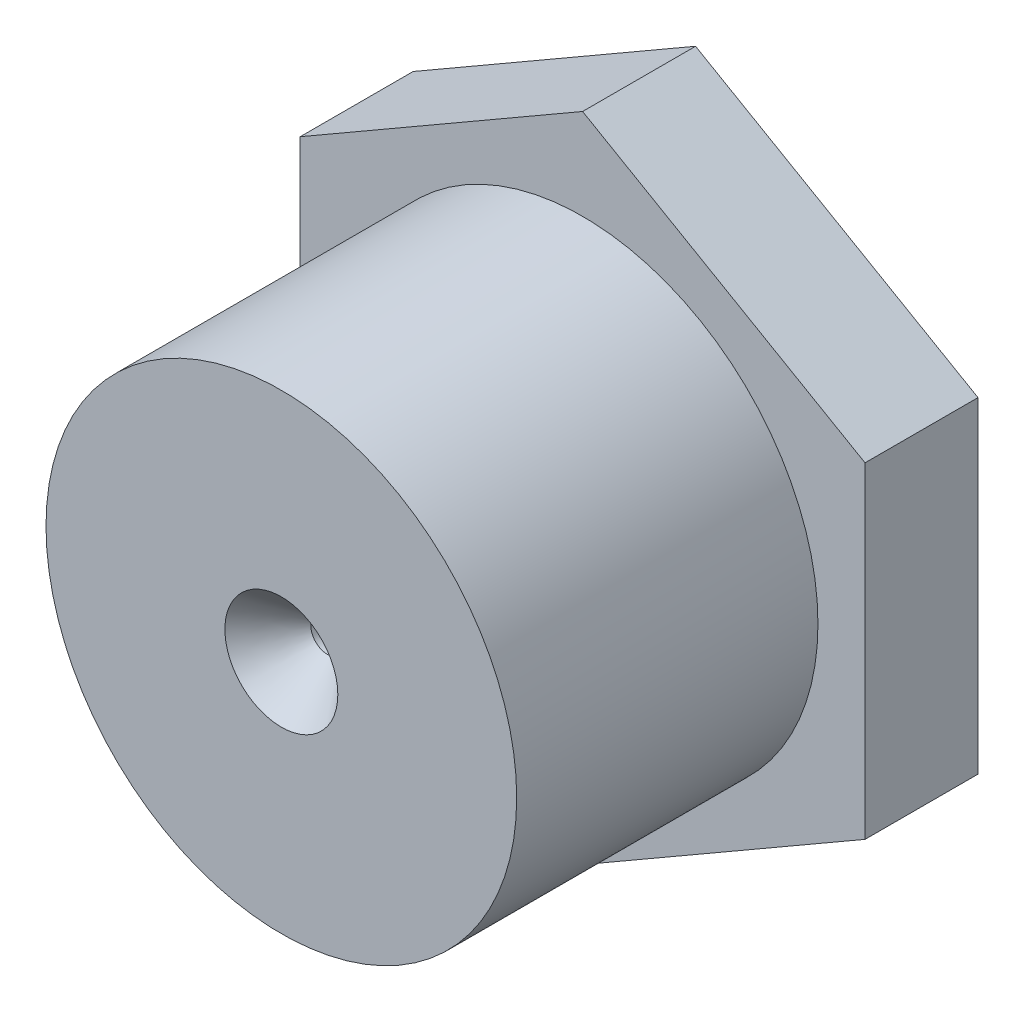
from build123d import *

# Parameters (mm, degrees)
ESTRUSIONE_ESTRUSIONE1_DEPTH = 6
SCHIZZO2_R                   = 12.5
ESTRUSIONE_ESTRUSIONE2_DEPTH = 16
FORO1_D                      = 1.75
FORO1_CSINK_D                = 6
FORO1_CSINK_ANGLE            = 82


with BuildPart() as part:
    # Schizzo1 → Estrusione-Estrusione1 (new body)
    with BuildSketch(Plane.XY):
        Polygon((0, 17.320508076), (-15, 8.660254038), (-15, -8.660254038), (0, -17.320508076), (15, -8.660254038), (15, 8.660254038), align=None)
    extrude(amount=ESTRUSIONE_ESTRUSIONE1_DEPTH)

    # Schizzo2 → Estrusione-Estrusione2 (add)
    with BuildSketch(Plane.XY.offset(6)):
        Circle(SCHIZZO2_R)
    extrude(amount=ESTRUSIONE_ESTRUSIONE2_DEPTH)

    # Foro1 (through all)
    with Locations(Plane.XY.offset(22)):
        with Locations((0, 0)):
            CounterSinkHole(FORO1_D / 2, FORO1_CSINK_D / 2, counter_sink_angle=FORO1_CSINK_ANGLE)

    # Schizzo7 → Taglia-Rivoluzione1 (revolve, cut)
    with BuildSketch(Plane(origin=(0, 0, 0), x_dir=(1, 0, 0), z_dir=(0, 1, 0))):
        Polygon((-1.5, 0), (0, -1.5), (0, 0), align=None)
    revolve(axis=Axis((0, 0, 1.5), (0, 0, -1)), mode=Mode.SUBTRACT)


solid = part.part
